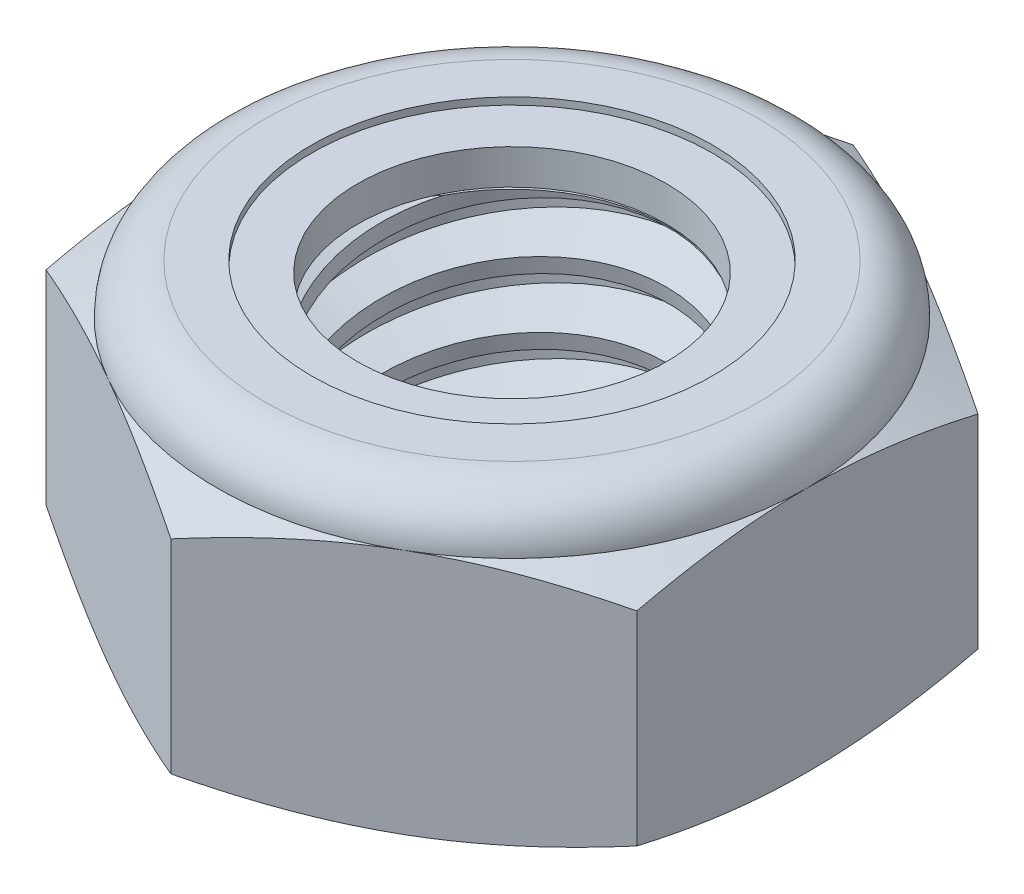
from build123d import *

# Parameters (mm, degrees)
EXTRUDE1_DEPTH       = 6.35
SKETCH2_W            = 3.9624
SKETCH2_H            = 6.35
LPATTERN1_COUNT      = 5
LPATTERN1_PITCH      = 1.411111111
LPATTERN1_COUNT_DIR2 = 2
LPATTERN1_PITCH_DIR2 = 1.411111111


with BuildPart() as part:
    # Sketch1 → Extrude1 (new body)
    with BuildSketch(Plane(origin=(0, 0, 0), x_dir=(1, 0, 0), z_dir=(0, 1, 0))):
        Polygon((0, 7.332348419), (-6.35, 3.666174209), (-6.35, -3.666174209), (0, -7.332348419), (6.35, -3.666174209), (6.35, 3.666174209), align=None)
    extrude(amount=EXTRUDE1_DEPTH)

    # Sketch4 → Cut-Revolve2 (revolve, cut)
    with BuildSketch(Plane(origin=(0, 0, 0), x_dir=(0, 0, -1), z_dir=(1, 0, 0))):
        Polygon((0, 6.35), (3.9624, 6.35), (3.318668226, 6.049822944), (3.318668226, 0.300177056), (3.9624, 0), (0, 0), align=None)
    revolve(axis=Axis((0, 6.35, 0), (0, 1, 0)), mode=Mode.SUBTRACT)


with BuildPart() as body_2:
    # Sketch2 → Revolve1 (revolve)
    with BuildSketch(Plane(origin=(0, 0, 0), x_dir=(0, 0, -1), z_dir=(1, 0, 0))):
        with Locations((1.9812, 3.175)):
            Rectangle(SKETCH2_W, SKETCH2_H)
    revolve(axis=Axis((0, -3.9624, 0), (0, 1, 0)))

    # Sketch3 → Cut-Revolve1 (revolve, cut)
    with BuildSketch(Plane(origin=(0, 0, 0), x_dir=(0, 0, -1), z_dir=(1, 0, 0))):
        Polygon((3.993321894, 6.176342646), (4.209775148, 4.960741167), (3.380512014, 5.260988826), (3.318668226, 5.608303534), align=None)
    cut_revolve1 = revolve(axis=Axis((0, 6.35, 0.26919352), (0, -0.984514133, -0.175305223)), mode=Mode.SUBTRACT)

    # LPattern1: Cut-Revolve1 5 × 2
    with Locations(*[Vector(0, -1, 0) * (i * LPATTERN1_PITCH) + Vector(0, 1, 0) * (j * LPATTERN1_PITCH_DIR2) for i in range(LPATTERN1_COUNT) for j in range(LPATTERN1_COUNT_DIR2) if (i, j) != (0, 0)]):
        add(cut_revolve1, mode=Mode.SUBTRACT)


with BuildPart() as part_1:
    add(part.part)

    # Combine1: cut body 2
    add(body_2.part, mode=Mode.SUBTRACT)

    # Sketch5 → Cut-Revolve3 (revolve, cut)
    with BuildSketch(Plane(origin=(0, 0, 0), x_dir=(0, 0, -1), z_dir=(1, 0, 0))):
        with BuildLine():
            Line((0, 0), (6.35, 0))
            Line((6.35, 0), (7.332348419, 0.458076591))
            Line((7.332348419, 0.458076591), (7.332348419, 4.833590076))
            Line((7.332348419, 4.833590076), (6.35, 5.291666667))
            ThreePointArc((6.35, 5.291666667), (6.040021343, 6.040021343), (5.291666667, 6.35))
            Line((5.291666667, 6.35), (5.291666667, 7.62))
            Line((5.291666667, 7.62), (8.602348419, 7.62))
            Line((8.602348419, 7.62), (8.602348419, -1.27))
            Line((8.602348419, -1.27), (0, -1.27))
            Line((0, -1.27), (0, 0))
        make_face()
    revolve(axis=Axis((0, 0, 0), (0, 1, 0)), mode=Mode.SUBTRACT)

    # Sketch6 → Cut-Revolve4 (revolve, cut)
    with BuildSketch(Plane(origin=(0, 0, 0), x_dir=(0, 0, -1), z_dir=(1, 0, 0))):
        with BuildLine():
            Line((0, 5.291666667), (6.1976, 5.291666667))
            ThreePointArc((6.1976, 5.291666667), (5.93225827, 5.93225827), (5.291666667, 6.1976))
            Line((5.291666667, 6.1976), (4.305167447, 6.1976))
            Line((4.305167447, 6.1976), (4.305167447, 7.62))
            Line((4.305167447, 7.62), (0, 7.62))
            Line((0, 7.62), (0, 5.291666667))
        make_face()
    revolve(axis=Axis((0, 7.62, 0), (0, 1, 0)), mode=Mode.SUBTRACT)


with BuildPart() as body_2_2:
    # Sketch7 → Revolve2 (revolve)
    with BuildSketch(Plane(origin=(0, 0, 0), x_dir=(0, 0, -1), z_dir=(1, 0, 0))):
        with BuildLine():
            Line((3.318668226, 5.367866667), (6.117893612, 5.367866667))
            ThreePointArc((6.117893612, 5.367866667), (5.850787282, 5.904725834), (5.291666667, 6.1214))
            Line((5.291666667, 6.1214), (3.318668226, 6.1214))
            Line((3.318668226, 6.1214), (3.318668226, 5.367866667))
        make_face()
    revolve(axis=Axis((0, 5.367866667, 0), (0, 1, 0)))


solid = Compound([part_1.part, body_2_2.part])
